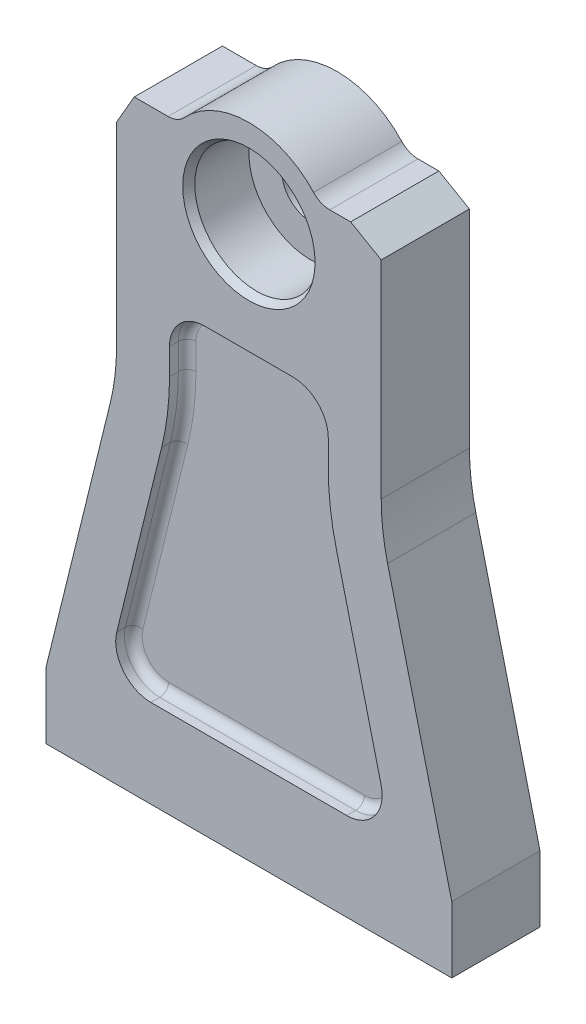
from build123d import *

# Parameters (mm, degrees)
SKETCH1_R                   = 6.5
BOSS_EXTRUDE1_DEPTH         = 10
SKETCH2_R                   = 14
CUT_EXTRUDE1_DEPTH          = 14
CHAMFER1_SIZE               = 1
CHAMFER1_SIZE2              = 1.732050808
CHAMFER2_SIZE               = 4
CHAMFER2_SIZE2              = 6.92820323
CHAMFER2_PART_2_SIZE        = 4
CHAMFER2_PART_2_SIZE2       = 6.92820323
FILLET1_R                   = 5
CUT_EXTRUDE2_DEPTH          = 4
FILLET2_R                   = 2
FILLET2_OF_MIRROR1_R        = 2
M10X1_25_TAPPED_HOLE1_D     = 8.8
M10X1_25_TAPPED_HOLE1_DEPTH = 20
M10X1_25_TAPPED_HOLE1_TIP   = 2.643786724


with BuildPart() as part:
    # Sketch1 → Boss-Extrude1 (new body, symmetric)
    with BuildSketch(Plane.XY):
        with BuildLine():
            Line((-46, 0), (46, 0))
            Line((46, 0), (46, 15))
            Line((46, 15), (31.449256053, 74.112397284))
            ThreePointArc((31.449256053, 74.112397284), (30.363636327, 80.044097084), (30, 86.06334964))
            Line((30, 86.06334964), (30, 137))
            Line((30, 137), (16, 137))
            ThreePointArc((16, 137), (0, 145), (-16, 137))
            Line((-16, 137), (-30, 137))
            Line((-30, 137), (-30, 86.06334964))
            ThreePointArc((-30, 86.06334964), (-30.363636327, 80.044097084), (-31.449256053, 74.112397284))
            Line((-31.449256053, 74.112397284), (-46, 15))
            Line((-46, 15), (-46, 0))
        make_face()
        with Locations((0, 125)):
            Circle(SKETCH1_R, mode=Mode.SUBTRACT)
    extrude(amount=BOSS_EXTRUDE1_DEPTH, both=True)

    # Sketch2 → Cut-Extrude1 (cut)
    with BuildSketch(Plane.XY.offset(10)):
        with Locations((0, 125)):
            Circle(SKETCH2_R)
    extrude(amount=-CUT_EXTRUDE1_DEPTH, mode=Mode.SUBTRACT)

    # Chamfer1
    chamfer1_edges = [part.edges().sort_by_distance(p)[0] for p in [
        (-14, 125, 10),
    ]]
    chamfer1_side = [part.faces().sort_by_distance(p)[0] for p in [
        (0, 59.441099991, 10),
    ]]
    chamfer(chamfer1_edges, length=CHAMFER1_SIZE, length2=CHAMFER1_SIZE2, reference=chamfer1_side[0])

    # Chamfer2
    chamfer2_edges = [part.edges().sort_by_distance(p)[0] for p in [
        (-30, 137, 0),
    ]]
    chamfer2_side = [part.faces().sort_by_distance(p)[0] for p in [
        (-23, 137, 0),
    ]]
    chamfer(chamfer2_edges, length=CHAMFER2_SIZE, length2=CHAMFER2_SIZE2, reference=chamfer2_side[0])

    # Chamfer2 part 2
    chamfer2_part_2_edges = [part.edges().sort_by_distance(p)[0] for p in [
        (30, 137, 0),
    ]]
    chamfer2_part_2_side = [part.faces().sort_by_distance(p)[0] for p in [
        (30, 111.53167482, 0),
    ]]
    chamfer(chamfer2_part_2_edges, length=CHAMFER2_PART_2_SIZE, length2=CHAMFER2_PART_2_SIZE2, reference=chamfer2_part_2_side[0])

    # Fillet1
    fillet1_edges = [part.edges().sort_by_distance(p)[0] for p in [
        (-16, 137, 0),
        (16, 137, 0),
    ]]
    fillet(fillet1_edges, radius=FILLET1_R)

    # Sketch3 → Cut-Extrude2 (cut)
    with BuildSketch(Plane.XY.offset(10)):
        with BuildLine():
            Line((-18, 92), (-18, 86.06334964))
            ThreePointArc((-18, 86.06334964), (-18.450909046, 78.59947647), (-19.797077506, 71.244168718))
            Line((-19.797077506, 71.244168718), (-29.971112298, 29.912152377))
            ThreePointArc((-29.971112298, 29.912152377), (-28.49970745, 23.065287193), (-22.202993266, 20))
            Line((-22.202993266, 20), (22.202993266, 20))
            ThreePointArc((22.202993266, 20), (28.49970745, 23.065287193), (29.971112298, 29.912152377))
            Line((29.971112298, 29.912152377), (19.797077506, 71.244168718))
            ThreePointArc((19.797077506, 71.244168718), (18.450909046, 78.59947647), (18, 86.06334964))
            Line((18, 86.06334964), (18, 92))
            ThreePointArc((18, 92), (15.656854249, 97.656854249), (10, 100))
            Line((10, 100), (-10, 100))
            ThreePointArc((-10, 100), (-15.656854249, 97.656854249), (-18, 92))
        make_face()
    cut_extrude2 = extrude(amount=-CUT_EXTRUDE2_DEPTH, mode=Mode.SUBTRACT)

    # Fillet2
    fillet2_edges = [part.edges().sort_by_distance(p)[0] for p in [
        (28.49970745, 23.065287193, 6),
        (0, 20, 6),
        (-28.49970745, 23.065287193, 6),
        (-24.884094902, 50.578160548, 6),
        (-18.450909046, 78.59947647, 6),
        (-18, 89.03167482, 6),
        (-15.656854249, 97.656854249, 6),
        (0, 100, 6),
        (15.656854249, 97.656854249, 6),
        (18, 89.03167482, 6),
        (18.450909046, 78.59947647, 6),
        (24.884094902, 50.578160548, 6),
    ]]
    fillet(fillet2_edges, radius=FILLET2_R)

    # Mirror1: Cut-Extrude2 across plane
    add(cut_extrude2.mirror(Plane.XY), mode=Mode.SUBTRACT)

    # Fillet2 of Mirror1
    fillet2_of_mirror1_edges = [part.edges().sort_by_distance(p)[0] for p in [
        (28.49970745, 23.065287193, -6),
        (0, 20, -6),
        (-28.49970745, 23.065287193, -6),
        (-24.884094902, 50.578160548, -6),
        (-18.450909046, 78.59947647, -6),
        (-18, 89.03167482, -6),
        (-15.656854249, 97.656854249, -6),
        (0, 100, -6),
        (15.656854249, 97.656854249, -6),
        (18, 89.03167482, -6),
        (18.450909046, 78.59947647, -6),
        (24.884094902, 50.578160548, -6),
    ]]
    fillet(fillet2_of_mirror1_edges, radius=FILLET2_OF_MIRROR1_R)

    # M10x1.25 Tapped Hole1
    with Locations(Plane(origin=(0, 0, 0), x_dir=(-1, 0, 0), z_dir=(0, -1, 0))):
        with Locations((30, 0), (-30, 0)):
            Hole(M10X1_25_TAPPED_HOLE1_D / 2, depth=M10X1_25_TAPPED_HOLE1_DEPTH)
            with Locations((0, 0, -(M10X1_25_TAPPED_HOLE1_DEPTH + M10X1_25_TAPPED_HOLE1_TIP / 2))):  # 118° drill point
                Cone(0, M10X1_25_TAPPED_HOLE1_D / 2, M10X1_25_TAPPED_HOLE1_TIP, mode=Mode.SUBTRACT)


solid = part.part
